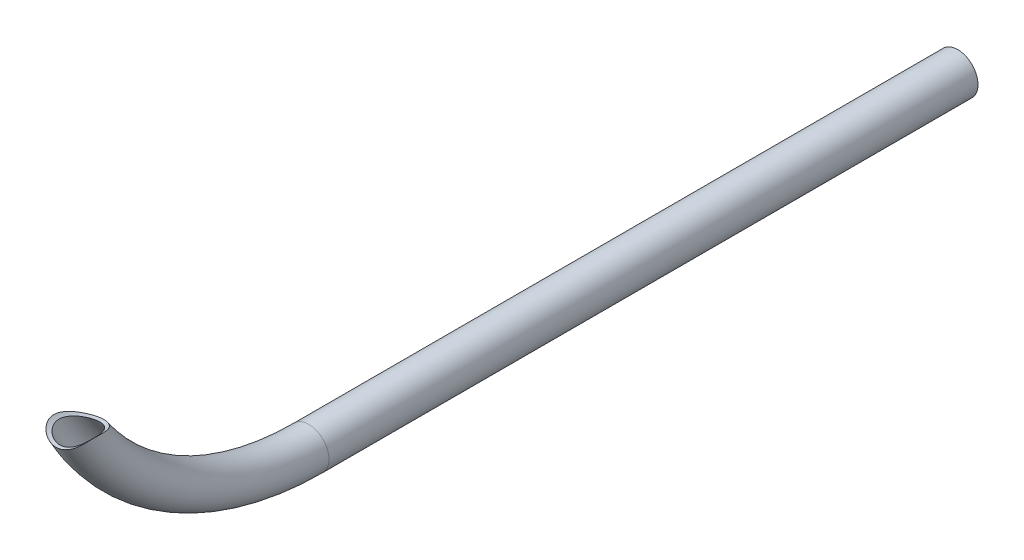
from build123d import *

# Parameters (mm, degrees)
SKETCH2_R          = 9.525
SKETCH2_R_2        = 7.9375
SKETCH5_R          = 12.7
CUT_EXTRUDE2_DEPTH = 32.061507661


with BuildPart() as part:
    # Sweep1: sweep along a path in Sketch3
    with BuildLine(Plane(origin=(0, 0, 0), x_dir=(0, 0, -1), z_dir=(1, 0, 0))) as sweep1_path:
        Line((0, 0), (-304.8, 0))
        ThreePointArc((-304.8, 0), (-370.874690339, 18.542011375), (-417.655559263, 68.753774857))
    # Sketch2 → Sweep1 (sweep)
    with BuildSketch(Plane.XY):
        Circle(SKETCH2_R)
        Circle(SKETCH2_R_2, mode=Mode.SUBTRACT)
    sweep(path=sweep1_path.line)

    # Sketch5 → Cut-Extrude2 (cut, through all)
    with BuildSketch(Plane(origin=(0, 0, 395.058218647), x_dir=(1, 1.32e-07, 0), z_dir=(0, 0, 1))):
        with Locations((9.499e-06, 72.23125)):
            Circle(SKETCH5_R)
    extrude(amount=CUT_EXTRUDE2_DEPTH, mode=Mode.SUBTRACT)


solid = part.part
